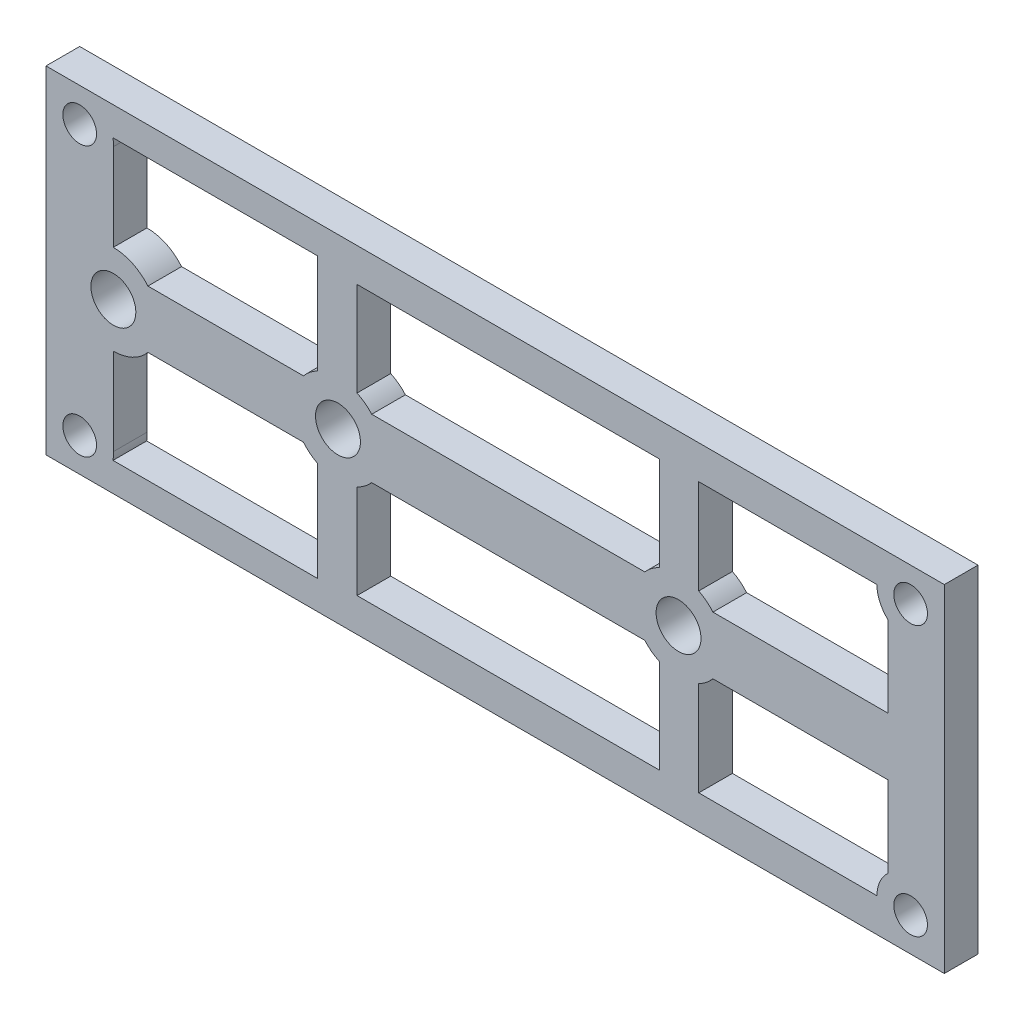
from build123d import *

# Parameters (mm, degrees)
SKETCH1_W           = 80
SKETCH1_H           = 30
BOSS_EXTRUDE1_DEPTH = 3
SKETCH2_R           = 1.5
SKETCH2_R_2         = 2
CUT_EXTRUDE2_DEPTH  = 4


with BuildPart() as part:
    # Sketch1 → Boss-Extrude1 (new body)
    with BuildSketch(Plane.XY):
        Rectangle(SKETCH1_W, SKETCH1_H)
    extrude(amount=BOSS_EXTRUDE1_DEPTH)

    # Sketch2 → Cut-Extrude2 (cut, through all)
    with BuildSketch(Plane.XY.offset(3)):
        with Locations((37, 12)):
            Circle(SKETCH2_R)
        with Locations((-37, 12)):
            Circle(SKETCH2_R)
        with Locations((37, -12)):
            Circle(SKETCH2_R)
        with Locations((-37, -12)):
            Circle(SKETCH2_R)
        with Locations((-14, 0)):
            Circle(SKETCH2_R_2)
        with Locations((-34, 0)):
            Circle(SKETCH2_R_2)
        with Locations((16.33, 0)):
            Circle(SKETCH2_R_2)
        with BuildLine():
            Line((-34.032472505, 12.440205142), (-15.8, 12.440205142))
            Line((-15.8, 12.440205142), (-15.8, 3.57211422))
            ThreePointArc((-15.8, 3.57211422), (-16.489437492, 3.130926536), (-17.074634359, 2.558637051))
            Line((-17.074634359, 2.558637051), (-30.925365641, 2.558637051))
            ThreePointArc((-30.925365641, 2.558637051), (-32.306522762, 3.623828755), (-34.009676412, 3.999988296))
            Line((-34.009676412, 3.999988296), (-34.009676412, 11.759241116))
            ThreePointArc((-34.009676412, 11.759241116), (-34.001679573, 12.100372396), (-34.032472505, 12.440205142))
        make_face()
        with BuildLine():
            Line((13.32333178, 2.638170998), (-10.99333178, 2.638170998))
            ThreePointArc((-10.99333178, 2.638170998), (-11.595928807, 3.196942555), (-12.3, 3.620773398))
            Line((-12.3, 3.620773398), (-12.3, 12))
            Line((-12.3, 12), (14.63, 12))
            Line((14.63, 12), (14.63, 3.620773398))
            ThreePointArc((14.63, 3.620773398), (13.925928807, 3.196942555), (13.32333178, 2.638170998))
        make_face()
        with BuildLine():
            Line((35, 2.571779372), (19.393649925, 2.571779372))
            ThreePointArc((19.393649925, 2.571779372), (18.812728358, 3.136249336), (18.13, 3.57211422))
            Line((18.13, 3.57211422), (18.13, 12))
            Line((18.13, 12), (34, 12))
            ThreePointArc((34, 12), (34.261387212, 10.775255129), (35, 9.763932023))
            Line((35, 9.763932023), (35, 2.571779372))
        make_face()
    cut_extrude2 = extrude(amount=-CUT_EXTRUDE2_DEPTH, mode=Mode.SUBTRACT)

    # Mirror1: Cut-Extrude2 across plane
    add(cut_extrude2.mirror(Plane.ZX), mode=Mode.SUBTRACT)


solid = part.part
